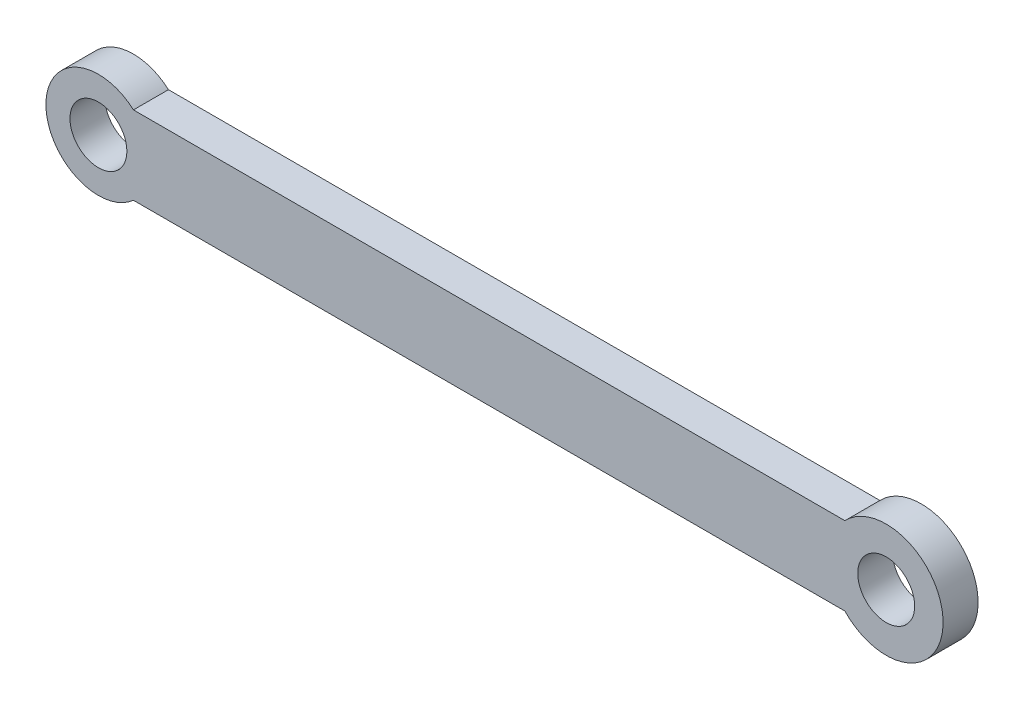
from build123d import *

# Parameters (mm, degrees)
SKETCH1_R           = 3.25
BOSS_EXTRUDE2_DEPTH = 4
SKETCH2_R           = 6.5
SKETCH2_R_2         = 3.25
BOSS_EXTRUDE3_DEPTH = 4
SKETCH3_R           = 3.25
CUT_EXTRUDE1_DEPTH  = 10


with BuildPart() as part:
    # Sketch1 → Boss-Extrude2 (new body)
    with BuildSketch(Plane.XY):
        with BuildLine():
            Line((4, -4.472135955), (4, 4.472135955))
            ThreePointArc((4, 4.472135955), (-6, 0), (4, -4.472135955))
        make_face()
        Circle(SKETCH1_R, mode=Mode.SUBTRACT)
        with BuildLine():
            ThreePointArc((6, 0), (5.477225575, 2.449489743), (4, 4.472135955))
            Line((4, 4.472135955), (4, -4.472135955))
            ThreePointArc((4, -4.472135955), (5.477225575, -2.449489743), (6, 0))
        make_face()
        with BuildLine():
            Line((90, 4.472135955), (4, 4.472135955))
            ThreePointArc((4, 4.472135955), (5.477225575, 2.449489743), (6, 0))
            ThreePointArc((6, 0), (5.477225575, -2.449489743), (4, -4.472135955))
            Line((4, -4.472135955), (90, -4.472135955))
            Line((90, -4.472135955), (90, 4.472135955))
        make_face()
    extrude(amount=BOSS_EXTRUDE2_DEPTH)

    # Sketch2 → Boss-Extrude3 (add)
    with BuildSketch(Plane.XY.offset(4)):
        with Locations((90, 0)):
            Circle(SKETCH2_R)
        with Locations((90, 0)):
            Circle(SKETCH2_R_2, mode=Mode.SUBTRACT)
    extrude(amount=-BOSS_EXTRUDE3_DEPTH)

    # Sketch3 → Cut-Extrude1 (cut)
    with BuildSketch(Plane.XY.offset(4)):
        with Locations((90, 0)):
            Circle(SKETCH3_R)
    extrude(amount=-CUT_EXTRUDE1_DEPTH, mode=Mode.SUBTRACT)


solid = part.part
